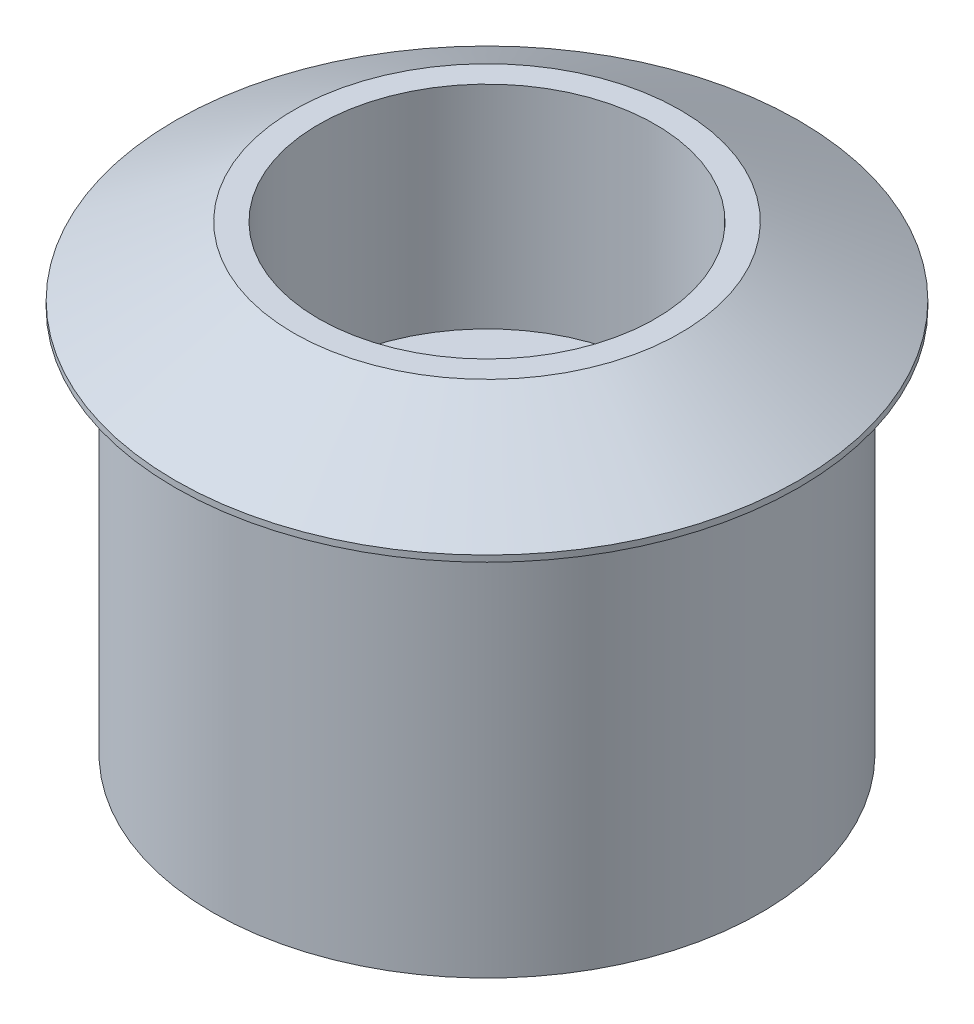
from build123d import *


with BuildPart() as part:
    # Esquisse1 → Révolution1 (revolve)
    with BuildSketch(Plane.XY, mode=Mode.PRIVATE) as r_volution1_sk:
        Polygon((4.1, 0), (4.1, 9.992413779), (6.75, 9.992413779), (6.75, 18.492413779), (7.75, 18.492413779), (12.5, 15.75), (12.5, 15.5), (11, 15.5), (11, 0), align=None)
    revolve(r_volution1_sk.sketch.rotate(Axis((0, 10.730531249, 0), (0, -1, 0)), 90), axis=Axis((0, 10.730531249, 0), (0, -1, 0)))  # turned: the seam where the file's is


solid = part.part
